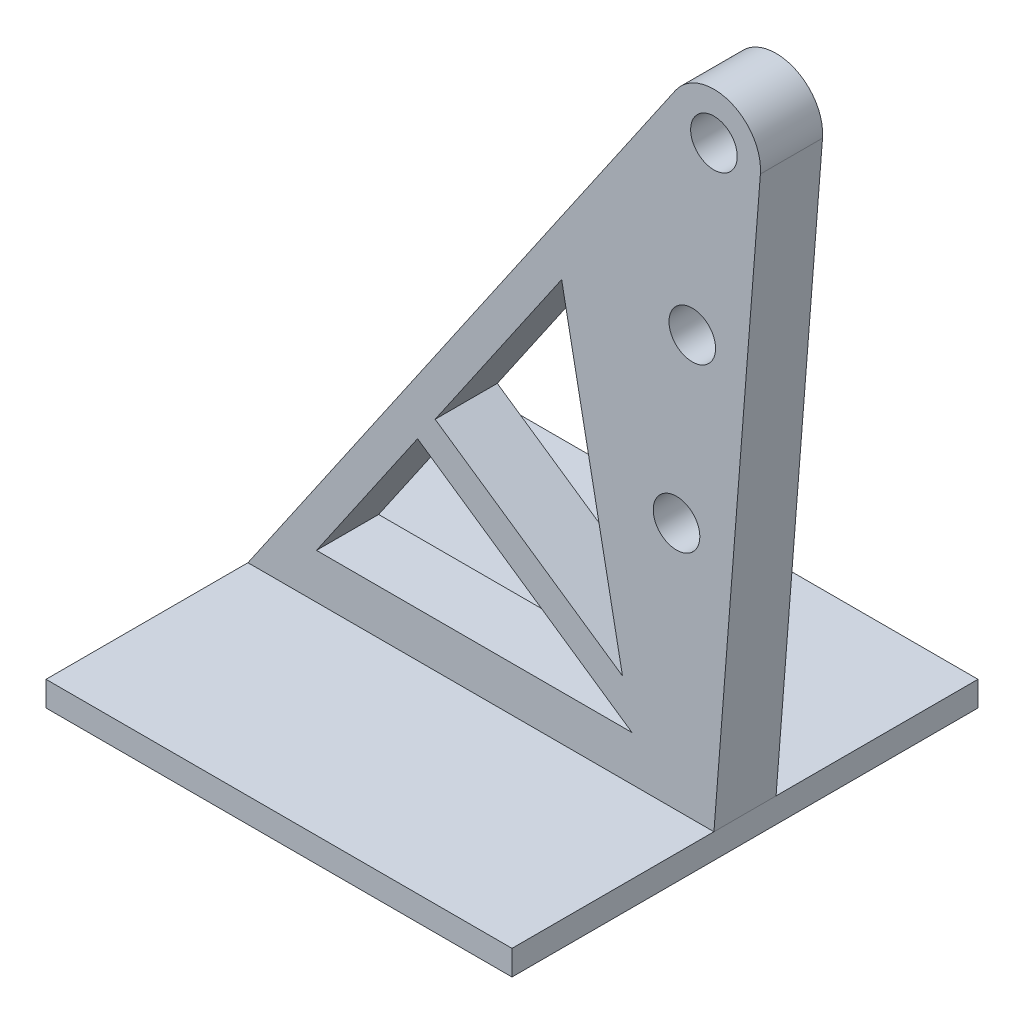
from build123d import *

# Parameters (mm, degrees)
SKETCH1_W           = 15
SKETCH1_H           = 15
BOSS_EXTRUDE1_DEPTH = 0.8
BOSS_EXTRUDE2_DEPTH = 1
SKETCH3_R           = 0.75
CUT_EXTRUDE2_DEPTH  = 9.5
SKETCH6_R           = 0.75
CUT_EXTRUDE3_DEPTH  = 70


with BuildPart() as part:
    # Sketch1 → Boss-Extrude1 (new body)
    with BuildSketch(Plane(origin=(0, 0, 0), x_dir=(1, 0, 0), z_dir=(0, 1, 0))):
        Rectangle(SKETCH1_W, SKETCH1_H)
    extrude(amount=BOSS_EXTRUDE1_DEPTH)

    # Sketch2 → Boss-Extrude2 (add, symmetric)
    with BuildSketch(Plane.XY):
        with BuildLine():
            Line((-7.5, 0.8), (6.263352991, 20.848942976))
            ThreePointArc((6.263352991, 20.848942976), (8.00009228, 21.414180933), (8.995415357, 19.8828125))
            Line((8.995415357, 19.8828125), (7.5, 0.8))
            Line((7.5, 0.8), (-7.5, 0.8))
        make_face()
    extrude(amount=BOSS_EXTRUDE2_DEPTH, both=True)

    # Sketch3 → Cut-Extrude2 (cut, through all)
    with BuildSketch(Plane(origin=(0, 0, -1), x_dir=(-1, 0, 0), z_dir=(0, 0, -1))):
        with Locations((-7.5, 20)):
            Circle(SKETCH3_R)
    extrude(amount=-CUT_EXTRUDE2_DEPTH, mode=Mode.SUBTRACT)

    # Sketch6 → Cut-Extrude3 (cut)
    with BuildSketch(Plane.XY.offset(1)):
        with Locations((6.803358906, 14.3)):
            Circle(SKETCH6_R)
        with Locations((6.295860941, 8.8)):
            Circle(SKETCH6_R)
        Polygon((-2.039936244, 6.986718852), (-5.293464788, 2.247335339), (4.863877808, 2.247335339), align=None)
        Polygon((-1.47397426, 7.811150191), (4.556357867, 3.671401287), (2.597993052, 13.742745529), align=None)
    extrude(amount=-CUT_EXTRUDE3_DEPTH, mode=Mode.SUBTRACT)


solid = part.part
